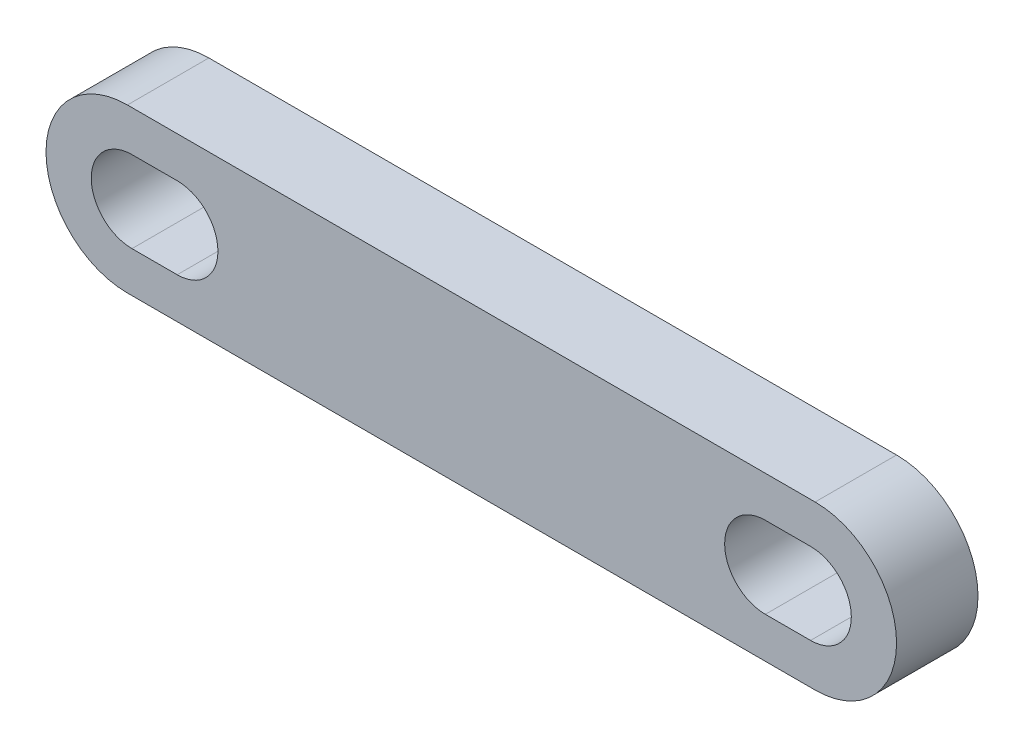
from build123d import *

# Parameters (mm, degrees)
SALIENTE_EXTRUIR2_DEPTH = 4.5


with BuildPart() as part:
    # Croquis1 → Saliente-Extruir2 (new body)
    with BuildSketch(Plane.XY):
        with BuildLine():
            Line((19, 4.5), (-19, 4.5))
            ThreePointArc((-19, 4.5), (-23.5, 0), (-19, -4.5))
            Line((-19, -4.5), (19, -4.5))
            ThreePointArc((19, -4.5), (23.5, 0), (19, 4.5))
        make_face()
        with BuildLine():
            Line((18.75, 2.25), (16.25, 2.25))
            ThreePointArc((16.25, 2.25), (14, 0), (16.25, -2.25))
            Line((16.25, -2.25), (18.75, -2.25))
            ThreePointArc((18.75, -2.25), (21, 0), (18.75, 2.25))
        make_face(mode=Mode.SUBTRACT)
        with BuildLine():
            Line((-16.25, 2.25), (-18.75, 2.25))
            ThreePointArc((-18.75, 2.25), (-21, 0), (-18.75, -2.25))
            Line((-18.75, -2.25), (-16.25, -2.25))
            ThreePointArc((-16.25, -2.25), (-14, 0), (-16.25, 2.25))
        make_face(mode=Mode.SUBTRACT)
    extrude(amount=SALIENTE_EXTRUIR2_DEPTH)


solid = part.part
